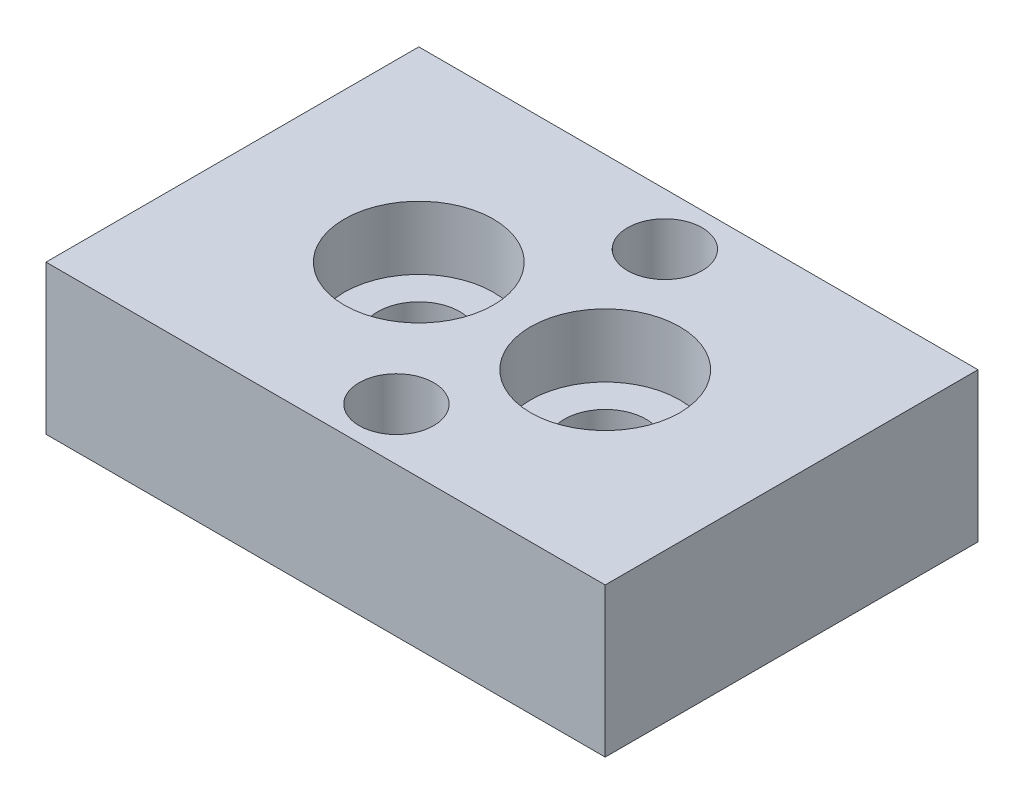
from build123d import *

# Parameters (mm, degrees)
SKETCH_1_W          = 15
SKETCH_1_H          = 10
EXTRUDE_1_DEPTH     = 4
SKETCH_2_R          = 1.1
CUT_EXTRUDE_1_DEPTH = 5
SKETCH_5_R          = 1
CUT_EXTRUDE_4_DEPTH = 3
SKETCH_3_R          = 2
CUT_EXTRUDE_5_DEPTH = 1.7


with BuildPart() as part:
    # 草图1 → 凸台-拉伸1 (new body)
    with BuildSketch(Plane(origin=(0, 0, 0), x_dir=(1, 0, 0), z_dir=(0, 1, 0))):
        with Locations((7.5, 5)):
            Rectangle(SKETCH_1_W, SKETCH_1_H)
    extrude(amount=EXTRUDE_1_DEPTH)

    # 草图2 → 切除-拉伸1 (cut, through all)
    with BuildSketch(Plane(origin=(0, 4, 0), x_dir=(1, 0, 0), z_dir=(0, 1, 0))):
        with Locations((5, 5)):
            Circle(SKETCH_2_R)
        with Locations((10, 5)):
            Circle(SKETCH_2_R)
    extrude(amount=-CUT_EXTRUDE_1_DEPTH, mode=Mode.SUBTRACT)

    # 草图5 → 切除-拉伸4 (cut)
    with BuildSketch(Plane(origin=(0, 4, 0), x_dir=(1, 0, 0), z_dir=(0, 1, 0))):
        with Locations((8, 8.6)):
            Circle(SKETCH_5_R)
        with Locations((8, 1.4)):
            Circle(SKETCH_5_R)
    extrude(amount=-CUT_EXTRUDE_4_DEPTH, mode=Mode.SUBTRACT)

    # 草图3 → 切除-拉伸5 (cut)
    with BuildSketch(Plane(origin=(0, 4, 0), x_dir=(1, 0, 0), z_dir=(0, 1, 0))):
        with Locations((5, 5)):
            Circle(SKETCH_3_R)
        with Locations((10, 5)):
            Circle(SKETCH_3_R)
    extrude(amount=-CUT_EXTRUDE_5_DEPTH, mode=Mode.SUBTRACT)


solid = part.part
